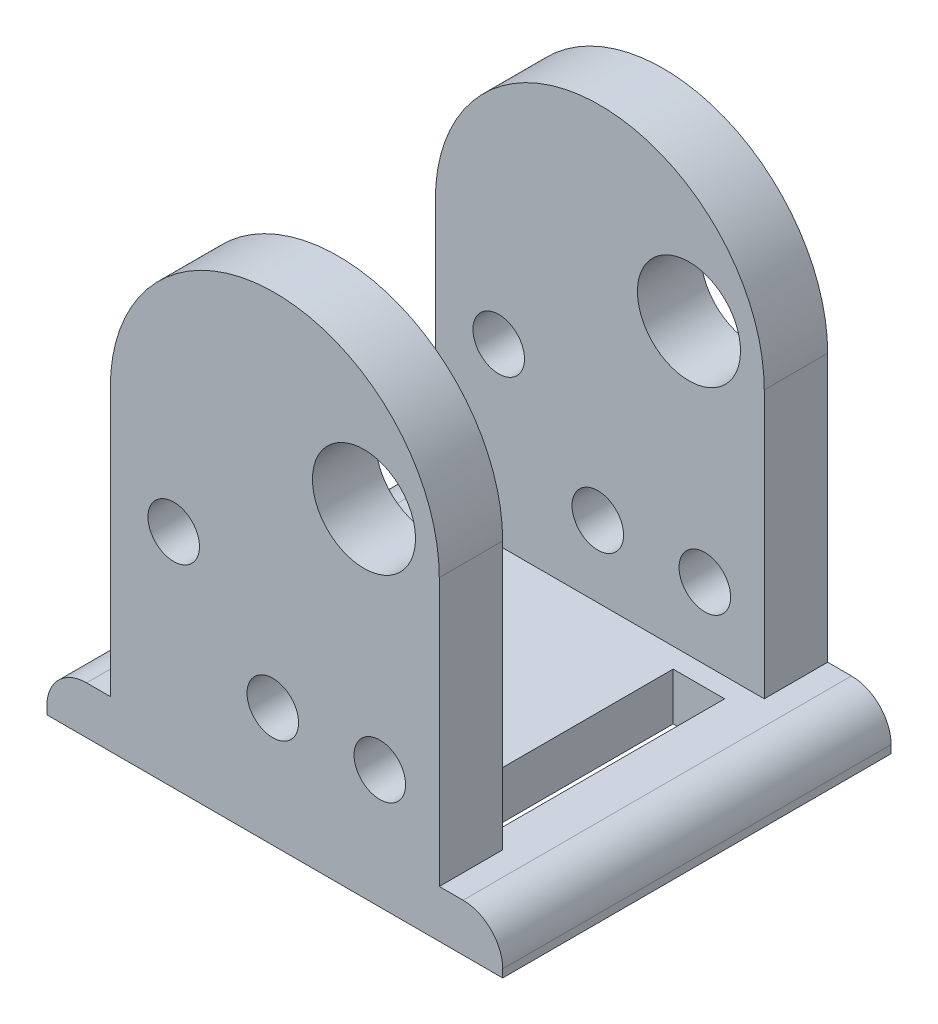
from build123d import *

# Parameters (mm, degrees)
BOSS_EXTRUDE1_DEPTH = 24.892
CUT_EXTRUDE1_REACH  = 27.146
SKETCH2_W           = 16.764
SKETCH2_H           = 27.686
SKETCH3_R           = 3.302
SKETCH3_R_2         = 1.651
CUT_EXTRUDE2_DEPTH  = 24.892
CUT_EXTRUDE3_REACH  = 32.734
SKETCH4_W           = 3.81
SKETCH4_H           = 14.224
SKETCH4_W_2         = 3.302
FILLET1_R           = 2.54


with BuildPart() as part:
    # Sketch1 → Boss-Extrude1 (new body)
    with BuildSketch(Plane.XY):
        with BuildLine():
            Line((-14.605, 0), (14.605, 0))
            Line((14.605, 0), (14.605, 3.048))
            Line((14.605, 3.048), (10.541, 3.048))
            Line((10.541, 3.048), (10.541, 20.193))
            ThreePointArc((10.541, 20.193), (0, 30.734), (-10.541, 20.193))
            Line((-10.541, 20.193), (-10.541, 3.048))
            Line((-10.541, 3.048), (-14.605, 3.048))
            Line((-14.605, 3.048), (-14.605, 0))
        make_face()
    extrude(amount=BOSS_EXTRUDE1_DEPTH)

    # Sketch2 → Cut-Extrude1 (cut, up to next)
    with BuildSketch(Plane.ZY.offset(10.541), mode=Mode.PRIVATE) as cut_extrude1_sk1:
        with Locations((12.446, 16.891)):
            Rectangle(SKETCH2_W, SKETCH2_H)
    cut_extrude1_tool1 = extrude(cut_extrude1_sk1.sketch, amount=-CUT_EXTRUDE1_REACH, mode=Mode.PRIVATE) & part.part
    add(cut_extrude1_tool1.solids().sort_by_distance((-10.541, 16.891, 12.446))[0], mode=Mode.SUBTRACT)

    # Sketch3 → Cut-Extrude2 (cut)
    with BuildSketch(Plane(origin=(0, 0, 0), x_dir=(-1, 0, 0), z_dir=(0, 0, -1))):
        with Locations((-5.715, 21.59)):
            Circle(SKETCH3_R)
        with Locations((-6.731, 7.62)):
            Circle(SKETCH3_R_2)
        with Locations((0.127, 7.62)):
            Circle(SKETCH3_R_2)
        with Locations((6.477, 14.224)):
            Circle(SKETCH3_R_2)
    extrude(amount=-CUT_EXTRUDE2_DEPTH, mode=Mode.SUBTRACT)

    # Sketch4 → Cut-Extrude3 (cut, up to next)
    with BuildSketch(Plane.XZ, mode=Mode.PRIVATE) as cut_extrude3_sk1:
        with Locations((-7.321818594, 12.446)):
            Rectangle(SKETCH4_W, SKETCH4_H)
    cut_extrude3_tool1 = extrude(cut_extrude3_sk1.sketch, amount=-CUT_EXTRUDE3_REACH, mode=Mode.PRIVATE) & part.part
    add(cut_extrude3_tool1.solids().sort_by_distance((-7.321819, 0, 12.446))[0], mode=Mode.SUBTRACT)
    # Sketch4 → Cut-Extrude3 (cut, up to next)
    with BuildSketch(Plane.XZ, mode=Mode.PRIVATE) as cut_extrude3_sk2:
        with Locations((7.62, 12.446)):
            Rectangle(SKETCH4_W_2, SKETCH4_H)
    cut_extrude3_tool2 = extrude(cut_extrude3_sk2.sketch, amount=-CUT_EXTRUDE3_REACH, mode=Mode.PRIVATE) & part.part
    add(cut_extrude3_tool2.solids().sort_by_distance((7.62, 0, 12.446))[0], mode=Mode.SUBTRACT)

    # Fillet1
    fillet1_edges = [part.edges().sort_by_distance(p)[0] for p in [
        (-14.605, 3.048, 12.446),
        (14.605, 3.048, 12.446),
    ]]
    fillet(fillet1_edges, radius=FILLET1_R)


solid = part.part
